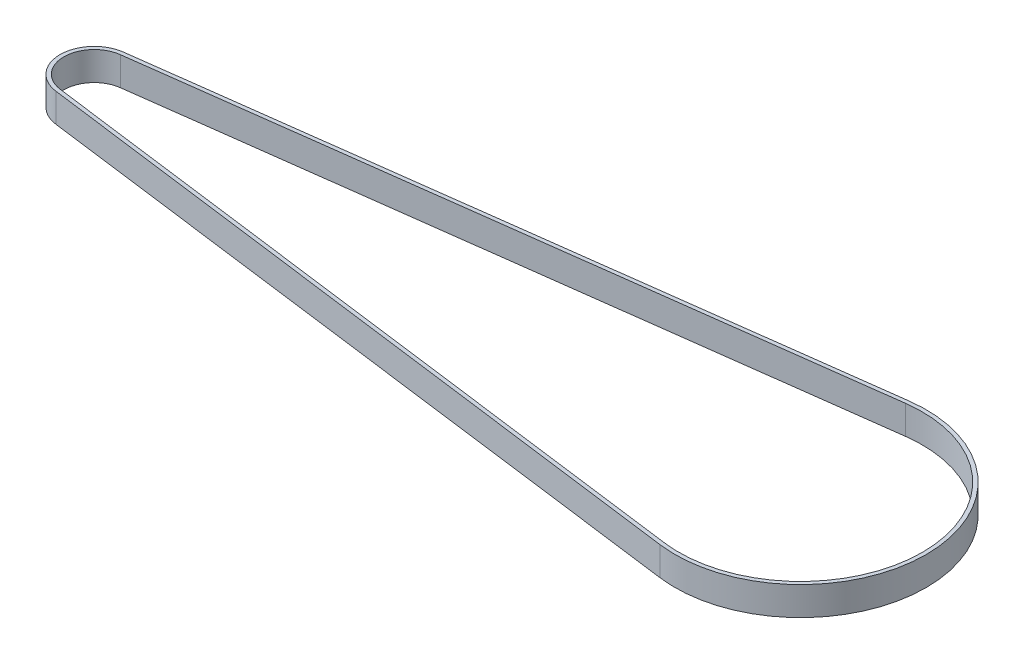
from build123d import *

# Parameters (mm, degrees)
BOSS_EXTRUDE1_DEPTH = 6


with BuildPart() as part:
    # Sketch1 → Boss-Extrude1 (new body)
    with BuildSketch(Plane(origin=(0, 0, 0), x_dir=(1, 0, 0), z_dir=(0, 1, 0))):
        with BuildLine():
            Line((-148.925152027, 7.089893774), (-3.403006757, 26.078909966))
            ThreePointArc((-3.403006757, 26.078909966), (26.3, 0), (-3.403006757, -26.078909966))
            Line((-3.403006757, -26.078909966), (-148.925152027, -7.089893774))
            ThreePointArc((-148.925152027, -7.089893774), (-155.15, 0), (-148.925152027, 7.089893774))
        make_face()
        with BuildLine():
            Line((-148.821638514, 6.296618946), (-3.299493243, 25.285635138))
            ThreePointArc((-3.299493243, 25.285635138), (25.5, 0), (-3.299493243, -25.285635138))
            Line((-3.299493243, -25.285635138), (-148.821638514, -6.296618946))
            ThreePointArc((-148.821638514, -6.296618946), (-154.35, 0), (-148.821638514, 6.296618946))
        make_face(mode=Mode.SUBTRACT)
    extrude(amount=BOSS_EXTRUDE1_DEPTH)


solid = part.part
